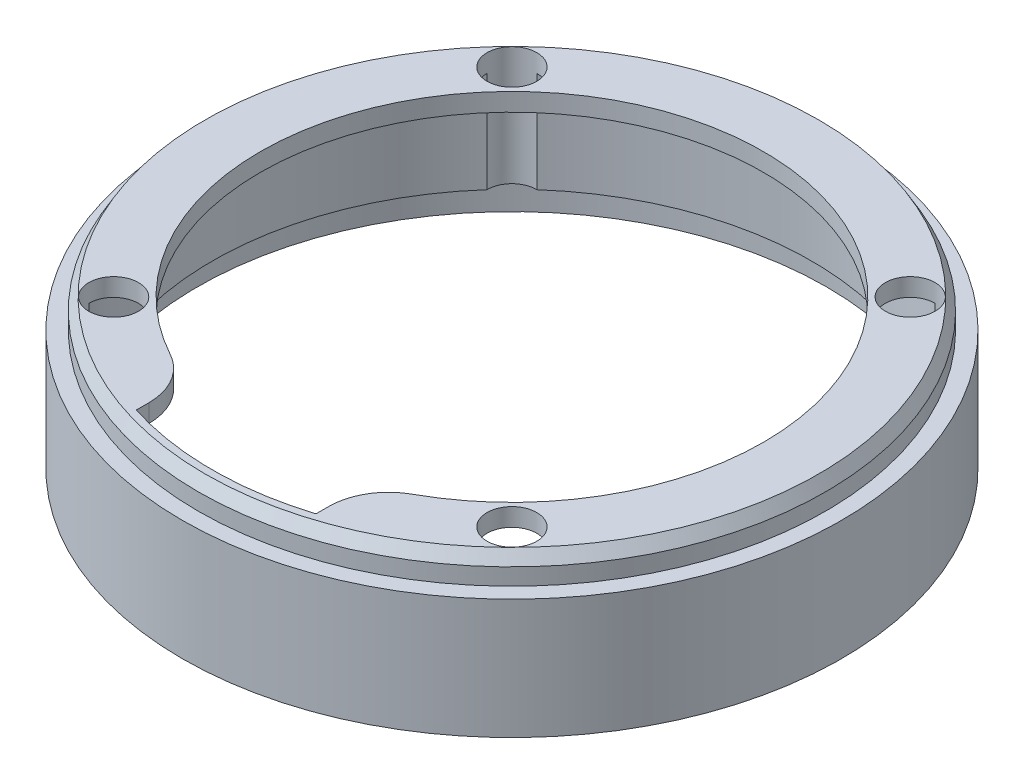
from build123d import *

# Parameters (mm, degrees)
SKETCH1_R           = 55
BOSS_EXTRUDE1_DEPTH = 24.8
SHELL1_T            = -5
SKETCH2_R           = 35
CUT_EXTRUDE1_DEPTH  = 6
SKETCH3_R           = 42
CUT_EXTRUDE2_DEPTH  = 25.8
SKETCH4_R           = 4.15
CUT_EXTRUDE3_DEPTH  = 25.8
SKETCH6_R           = 50
CUT_EXTRUDE4_DEPTH  = 2
CUT_EXTRUDE5_DEPTH  = 4
FILLET1_R           = 10
SKETCH8_OUTSIDE_W   = 143.506
SKETCH8_OUTSIDE_H   = 143.506
SKETCH8_OUTSIDE_R   = 52.35
CUT_EXTRUDE6_DEPTH  = 4.8
CHAMFER1_SIZE       = 2
CHAMFER1_SIZE2      = 1.154700538
SKETCH9_R           = 52.5
CUT_EXTRUDE7_DEPTH  = 5


with BuildPart() as part:
    # Sketch1 → Boss-Extrude1 (new body)
    with BuildSketch(Plane(origin=(0, 0, 0), x_dir=(1, 0, 0), z_dir=(0, 1, 0))):
        with Locations(Location((0, 0, 0), (0, 0, 270))):  # turned: the seam where the file's is
            Circle(SKETCH1_R)
    extrude(amount=BOSS_EXTRUDE1_DEPTH)

    # Shell1
    shell1_openings = [part.faces().sort_by_distance(p)[0] for p in [
        (0, 0, 0),
    ]]
    offset(amount=SHELL1_T, openings=shell1_openings, kind=Kind.INTERSECTION)

    # Sketch2 → Cut-Extrude1 (cut, through all)
    with BuildSketch(Plane.XZ.offset(-19.8)):
        with Locations(Location((0, 0, 0), (0, 0, 270))):  # turned: the seam where the file's is
            Circle(SKETCH2_R)
    extrude(amount=-CUT_EXTRUDE1_DEPTH, mode=Mode.SUBTRACT)

    # Sketch3 → Cut-Extrude2 (cut, through all)
    with BuildSketch(Plane(origin=(0, 24.8, 0), x_dir=(1, 0, 0), z_dir=(0, 1, 0))):
        with Locations(Location((0, 0, 0), (0, 0, 270))):  # turned: the seam where the file's is
            Circle(SKETCH3_R)
    extrude(amount=-CUT_EXTRUDE2_DEPTH, mode=Mode.SUBTRACT)

    # Sketch4 → Cut-Extrude3 (cut, through all)
    with BuildSketch(Plane(origin=(0, 24.8, 0), x_dir=(1, 0, 0), z_dir=(0, 1, 0))):
        with Locations(Location((-33.234018716, -33.234018716, 0), (0, 0, 270))):  # turned: the seam where the file's is
            Circle(SKETCH4_R)
        with Locations(Location((-33.234018716, 33.234018716, 0), (0, 0, 270))):  # turned: the seam where the file's is
            Circle(SKETCH4_R)
        with Locations(Location((33.234018716, 33.234018716, 0), (0, 0, 270))):  # turned: the seam where the file's is
            Circle(SKETCH4_R)
        with Locations(Location((33.234018716, -33.234018716, 0), (0, 0, 270))):  # turned: the seam where the file's is
            Circle(SKETCH4_R)
    extrude(amount=-CUT_EXTRUDE3_DEPTH, mode=Mode.SUBTRACT)

    # Sketch6 → Cut-Extrude4 (cut)
    with BuildSketch(Plane.XZ.offset(-19.8)):
        Circle(SKETCH6_R)
    extrude(amount=-CUT_EXTRUDE4_DEPTH, mode=Mode.SUBTRACT)

    # Sketch7 → Cut-Extrude5 (cut, through all)
    with BuildSketch(Plane.XZ.offset(-21.8)):
        with BuildLine():
            Line((15, 33.234018716), (15, 47.696960071))
            ThreePointArc((15, 47.696960071), (0, 50), (-15, 47.696960071))
            Line((-15, 47.696960071), (-15, 33.234018716))
            Line((-15, 33.234018716), (15, 33.234018716))
        make_face()
    extrude(amount=-CUT_EXTRUDE5_DEPTH, mode=Mode.SUBTRACT)

    # Fillet1
    fillet1_edges = [part.edges().sort_by_distance(p)[0] for p in [
        (-15, 23.3, 39.230090492),
        (15, 23.3, 39.230090492),
    ]]
    fillet(fillet1_edges, radius=FILLET1_R)

    # Sketch8 outside → Cut-Extrude6 (cut)
    with BuildSketch(Plane(origin=(0, 24.8, 0), x_dir=(1, 0, 0), z_dir=(0, 1, 0))):
        Rectangle(SKETCH8_OUTSIDE_W, SKETCH8_OUTSIDE_H)
        with Locations(Location((0, 0, 0), (0, 0, 270))):  # turned: the seam where the file's is
            Circle(SKETCH8_OUTSIDE_R, mode=Mode.SUBTRACT)
    extrude(amount=-CUT_EXTRUDE6_DEPTH, mode=Mode.SUBTRACT)

    # Chamfer1
    chamfer1_edges = [part.edges().sort_by_distance(p)[0] for p in [
        (0, 24.8, -52.35),
    ]]
    chamfer1_side = [part.faces().sort_by_distance(p)[0] for p in [
        (0, 22.4, -52.35),
    ]]
    chamfer(chamfer1_edges, length=CHAMFER1_SIZE, length2=CHAMFER1_SIZE2, reference=chamfer1_side[0])

    # Sketch9 → Cut-Extrude7 (cut)
    with BuildSketch(Plane.XZ):
        with Locations(Location((0, 0, 0), (0, 0, 270))):  # turned: the seam where the file's is
            Circle(SKETCH9_R)
    extrude(amount=-CUT_EXTRUDE7_DEPTH, mode=Mode.SUBTRACT)


solid = part.part
